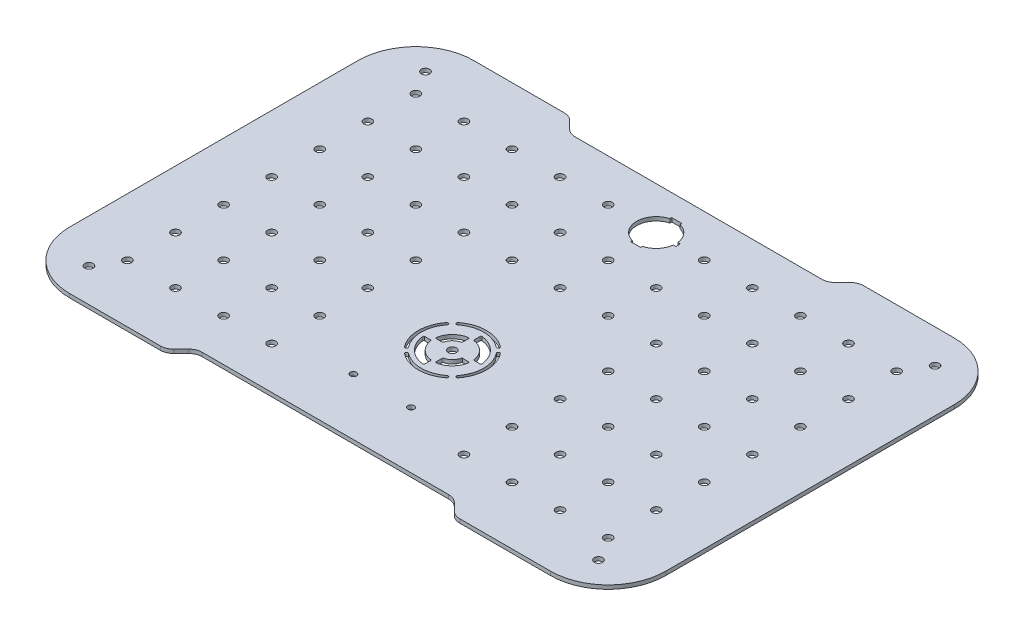
from build123d import *

# Parameters (mm, degrees)
BOSS_EXTRUDE1_DEPTH  = 2
SKETCH8_R            = 2.15
CUT_EXTRUDE11_DEPTH  = 3
CUT_EXTRUDE12_DEPTH  = 3
FILLET1_R            = 7
SKETCH11_R           = 2.15
CUT_EXTRUDE14_DEPTH  = 3
SKETCH10_R           = 2.15
CUT_EXTRUDE13_DEPTH  = 3
LPATTERN1_COUNT      = 7
LPATTERN1_PITCH      = 25
LPATTERN1_COUNT_DIR2 = 11
LPATTERN1_PITCH_DIR2 = 25
CUT_EXTRUDE18_DEPTH  = 3
CUT_EXTRUDE19_DEPTH  = 3
CUT_EXTRUDE20_DEPTH  = 3
CIRPATTERN4_COUNT    = 4
FILLET2_R            = 0.5
SKETCH18_R           = 1.65
CUT_EXTRUDE21_DEPTH  = 3
SKETCH19_R           = 10.15
CUT_EXTRUDE22_DEPTH  = 3
SKETCH20_W           = 2.5
SKETCH20_H           = 2.3
CUT_EXTRUDE23_DEPTH  = 3
SKETCH21_W           = 5.3
SKETCH21_H           = 21.5
CUT_EXTRUDE24_DEPTH  = 3


with BuildPart() as part:
    # Sketch1 → Boss-Extrude1 (new body)
    with BuildSketch(Plane(origin=(0, 0, 0), x_dir=(1, 0, 0), z_dir=(0, 1, 0))):
        with BuildLine():
            Line((125, -105), (-125, -105))
            ThreePointArc((-125, -105), (-146.213203436, -96.213203436), (-155, -75))
            Line((-155, -75), (-155, 75))
            ThreePointArc((-155, 75), (-146.213203436, 96.213203436), (-125, 105))
            Line((-125, 105), (125, 105))
            ThreePointArc((125, 105), (146.213203436, 96.213203436), (155, 75))
            Line((155, 75), (155, -75))
            ThreePointArc((155, -75), (146.213203436, -96.213203436), (125, -105))
        make_face()
    extrude(amount=-BOSS_EXTRUDE1_DEPTH)

    # Sketch8 → Cut-Extrude11 (cut, through all)
    with BuildSketch(Plane(origin=(0, 0, 0), x_dir=(1, 0, 0), z_dir=(0, 1, 0))):
        with Locations((-132.5, 87.5)):
            Circle(SKETCH8_R)
        with Locations((132.5, 87.5)):
            Circle(SKETCH8_R)
        with Locations((-132.5, -87.5)):
            Circle(SKETCH8_R)
        with Locations((132.5, -87.5)):
            Circle(SKETCH8_R)
    extrude(amount=-CUT_EXTRUDE11_DEPTH, mode=Mode.SUBTRACT)

    # Sketch9 → Cut-Extrude12 (cut, through all)
    with BuildSketch(Plane(origin=(0, 0, 0), x_dir=(1, 0, 0), z_dir=(0, 1, 0))):
        Polygon((-75, -105), (-67, -97), (67, -97), (75, -105), align=None)
    cut_extrude12 = extrude(amount=-CUT_EXTRUDE12_DEPTH, mode=Mode.SUBTRACT)

    # Mirror2: Cut-Extrude12 across plane
    add(cut_extrude12.mirror(Plane.XY), mode=Mode.SUBTRACT)

    # Fillet1
    fillet1_edges = [part.edges().sort_by_distance(p)[0] for p in [
        (75, -1, 105),
        (-75, -1, 105),
        (-67, -1, 97),
        (67, -1, 97),
        (-75, -1, -105),
        (75, -1, -105),
        (67, -1, -97),
        (-67, -1, -97),
    ]]
    fillet(fillet1_edges, radius=FILLET1_R)

    # Sketch11 → Cut-Extrude14 (cut, through all)
    with BuildSketch(Plane(origin=(0, 0, 0), x_dir=(1, 0, 0), z_dir=(0, 1, 0))):
        with Locations((0, -31)):
            Circle(SKETCH11_R)
    extrude(amount=-CUT_EXTRUDE14_DEPTH, mode=Mode.SUBTRACT)

    # Sketch10 → Cut-Extrude13 (cut, through all)
    with BuildSketch(Plane(origin=(0, 0, 0), x_dir=(1, 0, 0), z_dir=(0, 1, 0))):
        with Locations((-125, 75)):
            Circle(SKETCH10_R)
    cut_extrude13 = extrude(amount=-CUT_EXTRUDE13_DEPTH, mode=Mode.SUBTRACT)

    # LPattern1: Cut-Extrude13 7 × 11, 12 skipped
    with Locations(*[(j * LPATTERN1_PITCH_DIR2, 0, i * LPATTERN1_PITCH) for i in range(LPATTERN1_COUNT) for j in range(LPATTERN1_COUNT_DIR2) if (i, j) not in ((0, 0), (3, 4), (3, 5), (3, 6), (4, 4), (4, 5), (4, 6), (5, 4), (5, 5), (5, 6), (6, 4), (6, 5), (6, 6))]):
        add(cut_extrude13, mode=Mode.SUBTRACT)

    # Sketch15 → Cut-Extrude18 (cut, through all)
    with BuildSketch(Plane(origin=(0, 0, 0), x_dir=(1, 0, 0), z_dir=(0, 1, 0))):
        with BuildLine():
            Line((1, -17.050125629), (1, -21.050125629))
            ThreePointArc((1, -21.050125629), (7.071067812, -23.928932188), (9.949874371, -30))
            Line((9.949874371, -30), (13.949874371, -30))
            ThreePointArc((13.949874371, -30), (9.889362845, -21.110637155), (1, -17.050125629))
        make_face()
        with BuildLine():
            Line((-1, -40.949874371), (-1, -44.949874371))
            ThreePointArc((-1, -44.949874371), (-9.889362845, -40.889362845), (-13.949874371, -32))
            Line((-13.949874371, -32), (-9.949874371, -32))
            ThreePointArc((-9.949874371, -32), (-7.071067812, -38.071067812), (-1, -40.949874371))
        make_face()
    extrude(amount=-CUT_EXTRUDE18_DEPTH, mode=Mode.SUBTRACT)

    # Sketch16 → Cut-Extrude19 (cut, through all)
    with BuildSketch(Plane(origin=(0, 0, 0), x_dir=(1, 0, 0), z_dir=(0, 1, 0))):
        with BuildLine():
            Line((-1, -21.050125629), (-1, -25.050125629))
            ThreePointArc((-1, -25.050125629), (-4.266204697, -26.733795303), (-5.949874371, -30))
            Line((-5.949874371, -30), (-9.949874371, -30))
            ThreePointArc((-9.949874371, -30), (-7.071067812, -23.928932188), (-1, -21.050125629))
        make_face()
        with BuildLine():
            Line((1, -36.949874371), (1, -40.949874371))
            ThreePointArc((1, -40.949874371), (7.071067812, -38.071067812), (9.949874371, -32))
            Line((9.949874371, -32), (5.949874371, -32))
            ThreePointArc((5.949874371, -32), (4.266204697, -35.266204697), (1, -36.949874371))
        make_face()
    extrude(amount=-CUT_EXTRUDE19_DEPTH, mode=Mode.SUBTRACT)

    # Sketch17 → Cut-Extrude20 (cut, through all)
    with BuildSketch(Plane(origin=(0, 0, 0), x_dir=(1, 0, 0), z_dir=(0, 1, 0))):
        with BuildLine():
            ThreePointArc((10.927991187, -17.012809123), (0, -13.25), (-10.927991187, -17.012809123))
            ThreePointArc((-10.927991187, -17.012809123), (-11.057253146, -18.065563295), (-10.004498974, -18.194825254))
            ThreePointArc((-10.004498974, -18.194825254), (0, -14.75), (10.004498974, -18.194825254))
            ThreePointArc((10.004498974, -18.194825254), (11.057253146, -18.065563295), (10.927991187, -17.012809123))
        make_face()
    cut_extrude20 = extrude(amount=-CUT_EXTRUDE20_DEPTH, mode=Mode.SUBTRACT)

    # CirPattern4: Cut-Extrude20 ×4 about axis
    cirpattern4_axis = Axis((0, 0, 31), (0, 1, 0))
    for i in range(1, CIRPATTERN4_COUNT):
        add(cut_extrude20.rotate(cirpattern4_axis, i * 360 / CIRPATTERN4_COUNT), mode=Mode.SUBTRACT)

    # Fillet2
    fillet2_edges = [part.edges().sort_by_distance(p)[0] for p in [
        (1, -1, 17.050125629),
        (13.949874371, -1, 30),
        (9.949874371, -1, 30),
        (1, -1, 21.050125629),
        (-9.949874371, -1, 32),
        (-1, -1, 40.949874371),
        (-1, -1, 44.949874371),
        (-13.949874371, -1, 32),
        (-9.949874371, -1, 30),
        (-1, -1, 21.050125629),
        (-1, -1, 25.050125629),
        (-5.949874371, -1, 30),
        (1, -1, 36.949874371),
        (5.949874371, -1, 32),
        (9.949874371, -1, 32),
        (1, -1, 40.949874371),
    ]]
    fillet(fillet2_edges, radius=FILLET2_R)

    # Sketch18 → Cut-Extrude21 (cut, through all)
    with BuildSketch(Plane(origin=(0, 0, 0), x_dir=(1, 0, 0), z_dir=(0, 1, 0))):
        with Locations((15, -67.5)):
            Circle(SKETCH18_R)
        with Locations((-15, -67.5)):
            Circle(SKETCH18_R)
    extrude(amount=-CUT_EXTRUDE21_DEPTH, mode=Mode.SUBTRACT)

    # Sketch19 → Cut-Extrude22 (cut, through all)
    with BuildSketch(Plane(origin=(0, 0, 0), x_dir=(1, 0, 0), z_dir=(0, 1, 0))):
        with Locations((0, 75)):
            Circle(SKETCH19_R)
    extrude(amount=-CUT_EXTRUDE22_DEPTH, mode=Mode.SUBTRACT)

    # Sketch20 → Cut-Extrude23 (cut, through all)
    with BuildSketch(Plane(origin=(0, 0, 0), x_dir=(1, 0, 0), z_dir=(0, 1, 0))):
        with Locations((10.15, 75)):
            Rectangle(SKETCH20_W, SKETCH20_H)
    extrude(amount=-CUT_EXTRUDE23_DEPTH, mode=Mode.SUBTRACT)

    # Sketch21 → Cut-Extrude24 (cut, through all)
    with BuildSketch(Plane(origin=(0, 0, 0), x_dir=(1, 0, 0), z_dir=(0, 1, 0))):
        with Locations((0, 75)):
            Rectangle(SKETCH21_W, SKETCH21_H)
    extrude(amount=-CUT_EXTRUDE24_DEPTH, mode=Mode.SUBTRACT)


solid = part.part
